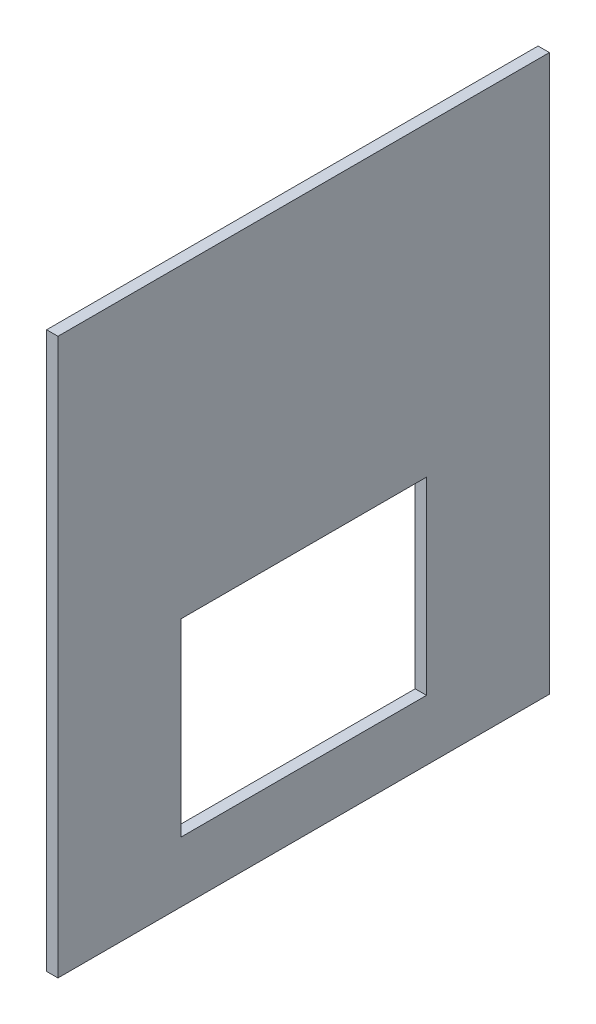
from build123d import *

# Parameters (mm, degrees)
SKETCH1_W           = 130
SKETCH1_H           = 147
SKETCH1_W_2         = 65
SKETCH1_H_2         = 50
BOSS_EXTRUDE2_DEPTH = 3


with BuildPart() as part:
    # Sketch1 → Boss-Extrude2 (new body)
    with BuildSketch(Plane(origin=(0, 0, 0), x_dir=(0, 0, -1), z_dir=(1, 0, 0))):
        with Locations((65, 73.5)):
            Rectangle(SKETCH1_W, SKETCH1_H)
        with Locations((65, 41)):
            Rectangle(SKETCH1_W_2, SKETCH1_H_2, mode=Mode.SUBTRACT)
    extrude(amount=BOSS_EXTRUDE2_DEPTH)


solid = part.part
